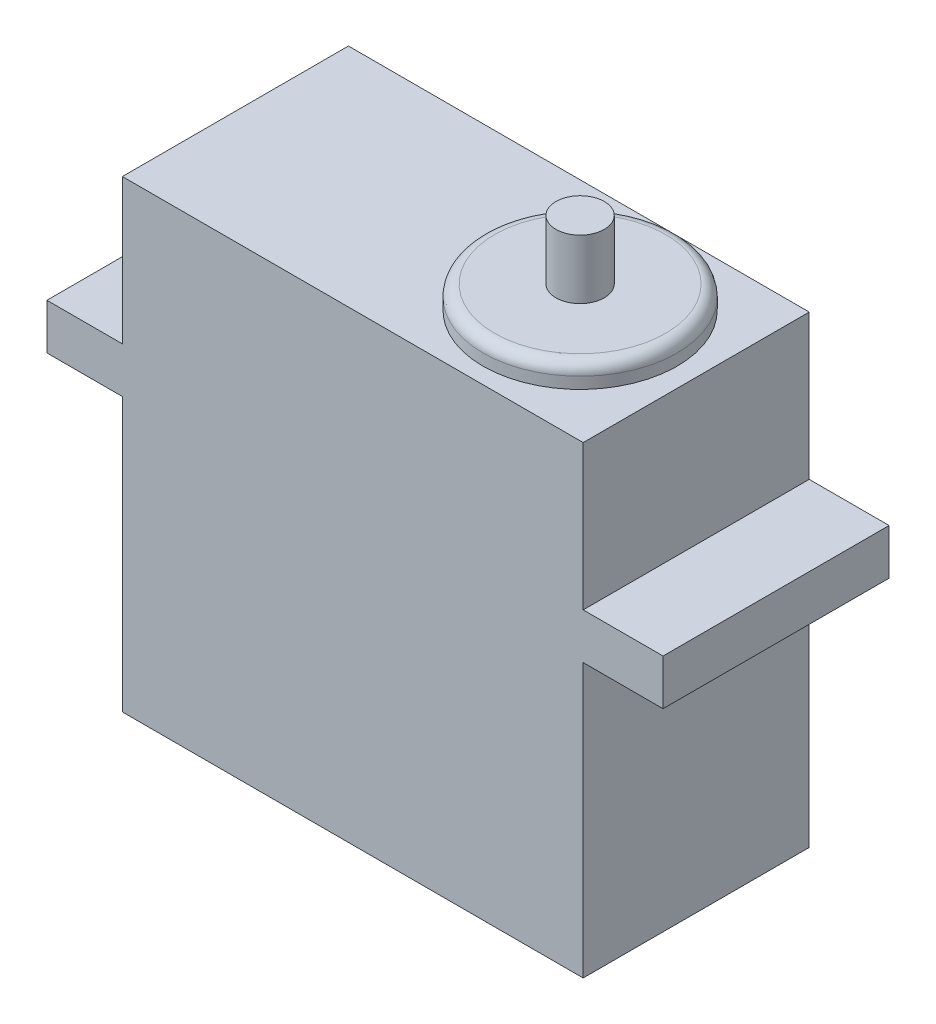
from build123d import *

# Parameters (mm, degrees)
SKETCH1_W                = 40.386
SKETCH1_H                = 19.812
BOSS_EXTRUDE1_DEPTH      = 40.64
SKETCH2_W                = 19.812
SKETCH2_H                = 4
BOSS_EXTRUDE2_DEPTH      = 7
BOSS_EXTRUDE2_DEPTH_BACK = 47
SKETCH3_R                = 8.5
BOSS_EXTRUDE3_DEPTH      = 2
FILLET1_R                = 1
SKETCH4_R                = 2.117245373
BOSS_EXTRUDE4_DEPTH      = 5.2


with BuildPart() as part:
    # Sketch1 → Boss-Extrude1 (new body)
    with BuildSketch(Plane(origin=(0, 0, 0), x_dir=(1, 0, 0), z_dir=(0, 1, 0))):
        Rectangle(SKETCH1_W, SKETCH1_H)
    extrude(amount=BOSS_EXTRUDE1_DEPTH)

    # Sketch2 → Boss-Extrude2 (add, two sides)
    with BuildSketch(Plane(origin=(20.193, 0, 0), x_dir=(0, 0, -1), z_dir=(1, 0, 0))) as boss_extrude2_sk:
        with Locations((0, 25.94)):
            Rectangle(SKETCH2_W, SKETCH2_H)
    extrude(amount=BOSS_EXTRUDE2_DEPTH)
    extrude(boss_extrude2_sk.sketch, amount=-BOSS_EXTRUDE2_DEPTH_BACK)

    # Sketch3 → Boss-Extrude3 (add)
    with BuildSketch(Plane(origin=(0, 40.64, 0), x_dir=(1, 0, 0), z_dir=(0, 1, 0))):
        with Locations((10.018571985, 0)):
            Circle(SKETCH3_R)
    extrude(amount=BOSS_EXTRUDE3_DEPTH)

    # Fillet1
    fillet1_edges = [part.edges().sort_by_distance(p)[0] for p in [
        (1.518571985, 42.64, 0),
    ]]
    fillet(fillet1_edges, radius=FILLET1_R)

    # Sketch4 → Boss-Extrude4 (add)
    with BuildSketch(Plane(origin=(0, 42.64, 0), x_dir=(1, 0, 0), z_dir=(0, 1, 0))):
        with Locations((10.018571985, 0)):
            Circle(SKETCH4_R)
    extrude(amount=BOSS_EXTRUDE4_DEPTH)


solid = part.part
